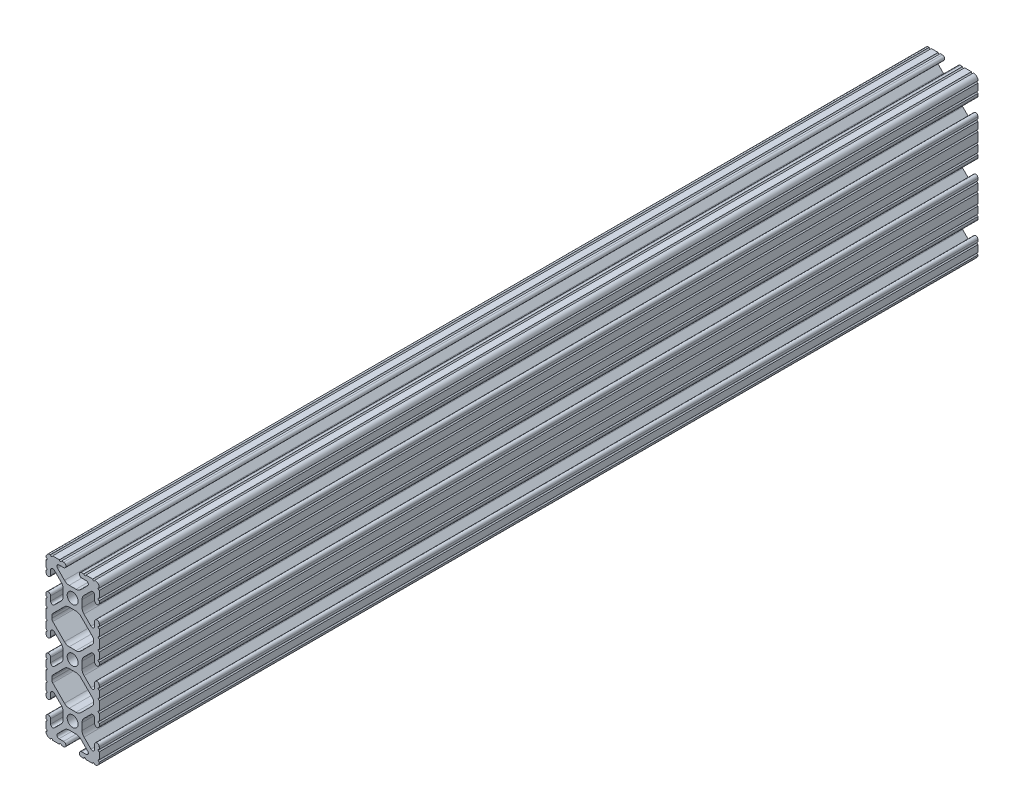
from build123d import *

# Parameters (mm, degrees)
SKETCH1_R           = 2.6035
BOSS_EXTRUDE1_DEPTH = 419.1


with BuildPart() as part:
    # Sketch1 → Boss-Extrude1 (new body)
    with BuildSketch(Plane.XY):
        with BuildLine():
            Line((-6.3246, 38.1), (-9.5504, 38.1))
            ThreePointArc((-9.5504, 38.1), (-10.0584, 37.592), (-10.5664, 38.1))
            ThreePointArc((-10.5664, 38.1), (-12.082677406, 37.482677406), (-12.7, 35.9664))
            ThreePointArc((-12.7, 35.9664), (-12.192, 35.4584), (-12.7, 34.9504))
            Line((-12.7, 34.9504), (-12.7, 31.7246))
            ThreePointArc((-12.7, 31.7246), (-12.192, 31.2166), (-12.7, 30.7086))
            Line((-12.7, 30.7086), (-12.7, 29.702307889))
            ThreePointArc((-12.7, 29.702307889), (-11.5951, 28.597407889), (-10.4902, 29.702307889))
            Line((-10.4902, 29.702307889), (-10.4902, 31.874794456))
            ThreePointArc((-10.4902, 31.874794456), (-9.863006367, 32.813456061), (-8.75577951, 32.593214945))
            Line((-8.75577951, 32.593214945), (-5.43843597, 29.275871405))
            ThreePointArc((-5.43843597, 29.275871405), (-4.750182484, 28.245827272), (-4.5085, 27.030807374))
            Line((-4.5085, 27.030807374), (-4.5085, 23.769192626))
            ThreePointArc((-4.5085, 23.769192626), (-4.750182484, 22.554172728), (-5.43843597, 21.524128595))
            Line((-5.43843597, 21.524128595), (-8.75577951, 18.206785055))
            ThreePointArc((-8.75577951, 18.206785055), (-9.863006367, 17.986543939), (-10.4902, 18.925205544))
            Line((-10.4902, 18.925205544), (-10.4902, 21.097692111))
            ThreePointArc((-10.4902, 21.097692111), (-11.5951, 22.202592111), (-12.7, 21.097692111))
            Line((-12.7, 21.097692111), (-12.7, 20.0914))
            ThreePointArc((-12.7, 20.0914), (-12.192, 19.5834), (-12.7, 19.0754))
            Line((-12.7, 19.0754), (-12.7, 15.8496))
            ThreePointArc((-12.7, 15.8496), (-12.192, 15.3416), (-12.7, 14.8336))
            Line((-12.7, 14.8336), (-12.7, 10.5664))
            ThreePointArc((-12.7, 10.5664), (-12.192, 10.0584), (-12.7, 9.5504))
            Line((-12.7, 9.5504), (-12.7, 6.3246))
            ThreePointArc((-12.7, 6.3246), (-12.192, 5.8166), (-12.7, 5.3086))
            Line((-12.7, 5.3086), (-12.7, 4.302307889))
            ThreePointArc((-12.7, 4.302307889), (-11.5951, 3.197407889), (-10.4902, 4.302307889))
            Line((-10.4902, 4.302307889), (-10.4902, 6.474794456))
            ThreePointArc((-10.4902, 6.474794456), (-9.863006367, 7.413456061), (-8.75577951, 7.193214945))
            Line((-8.75577951, 7.193214945), (-5.43843597, 3.875871405))
            ThreePointArc((-5.43843597, 3.875871405), (-4.750182484, 2.845827272), (-4.5085, 1.630807374))
            Line((-4.5085, 1.630807374), (-4.5085, -1.630807374))
            ThreePointArc((-4.5085, -1.630807374), (-4.750182484, -2.845827272), (-5.43843597, -3.875871405))
            Line((-5.43843597, -3.875871405), (-8.75577951, -7.193214945))
            ThreePointArc((-8.75577951, -7.193214945), (-9.863006367, -7.413456061), (-10.4902, -6.474794456))
            Line((-10.4902, -6.474794456), (-10.4902, -4.302307889))
            ThreePointArc((-10.4902, -4.302307889), (-11.5951, -3.197407889), (-12.7, -4.302307889))
            Line((-12.7, -4.302307889), (-12.7, -5.3086))
            ThreePointArc((-12.7, -5.3086), (-12.192, -5.8166), (-12.7, -6.3246))
            Line((-12.7, -6.3246), (-12.7, -9.5504))
            ThreePointArc((-12.7, -9.5504), (-12.192, -10.0584), (-12.7, -10.5664))
            Line((-12.7, -10.5664), (-12.7, -14.8336))
            ThreePointArc((-12.7, -14.8336), (-12.192, -15.3416), (-12.7, -15.8496))
            Line((-12.7, -15.8496), (-12.7, -19.0754))
            ThreePointArc((-12.7, -19.0754), (-12.192, -19.5834), (-12.7, -20.0914))
            Line((-12.7, -20.0914), (-12.7, -21.097692111))
            ThreePointArc((-12.7, -21.097692111), (-11.5951, -22.202592111), (-10.4902, -21.097692111))
            Line((-10.4902, -21.097692111), (-10.4902, -18.925205544))
            ThreePointArc((-10.4902, -18.925205544), (-9.863006367, -17.986543939), (-8.75577951, -18.206785055))
            Line((-8.75577951, -18.206785055), (-5.43843597, -21.524128595))
            ThreePointArc((-5.43843597, -21.524128595), (-4.750182484, -22.554172728), (-4.5085, -23.769192626))
            Line((-4.5085, -23.769192626), (-4.5085, -27.030807374))
            ThreePointArc((-4.5085, -27.030807374), (-4.750182484, -28.245827272), (-5.43843597, -29.275871405))
            Line((-5.43843597, -29.275871405), (-8.75577951, -32.593214945))
            ThreePointArc((-8.75577951, -32.593214945), (-9.863006367, -32.813456061), (-10.4902, -31.874794456))
            Line((-10.4902, -31.874794456), (-10.4902, -29.702307889))
            ThreePointArc((-10.4902, -29.702307889), (-11.5951, -28.597407889), (-12.7, -29.702307889))
            Line((-12.7, -29.702307889), (-12.7, -30.7086))
            ThreePointArc((-12.7, -30.7086), (-12.192, -31.2166), (-12.7, -31.7246))
            Line((-12.7, -31.7246), (-12.7, -34.9504))
            ThreePointArc((-12.7, -34.9504), (-12.192, -35.4584), (-12.7, -35.9664))
            ThreePointArc((-12.7, -35.9664), (-12.082677406, -37.482677406), (-10.5664, -38.1))
            ThreePointArc((-10.5664, -38.1), (-10.0584, -37.592), (-9.5504, -38.1))
            Line((-9.5504, -38.1), (-6.3246, -38.1))
            ThreePointArc((-6.3246, -38.1), (-5.8166, -37.592), (-5.3086, -38.1))
            Line((-5.3086, -38.1), (-4.302307889, -38.1))
            ThreePointArc((-4.302307889, -38.1), (-3.197407889, -36.9951), (-4.302307889, -35.8902))
            Line((-4.302307889, -35.8902), (-6.474794456, -35.8902))
            ThreePointArc((-6.474794456, -35.8902), (-7.413456061, -35.263006367), (-7.193214945, -34.15577951))
            Line((-7.193214945, -34.15577951), (-3.875871405, -30.83843597))
            ThreePointArc((-3.875871405, -30.83843597), (-2.845827272, -30.150182484), (-1.630807374, -29.9085))
            Line((-1.630807374, -29.9085), (1.630807374, -29.9085))
            ThreePointArc((1.630807374, -29.9085), (2.845827272, -30.150182484), (3.875871405, -30.83843597))
            Line((3.875871405, -30.83843597), (7.193214945, -34.15577951))
            ThreePointArc((7.193214945, -34.15577951), (7.413456061, -35.263006367), (6.474794456, -35.8902))
            Line((6.474794456, -35.8902), (4.302307889, -35.8902))
            ThreePointArc((4.302307889, -35.8902), (3.197407889, -36.9951), (4.302307889, -38.1))
            Line((4.302307889, -38.1), (5.3086, -38.1))
            ThreePointArc((5.3086, -38.1), (5.8166, -37.592), (6.3246, -38.1))
            Line((6.3246, -38.1), (9.5504, -38.1))
            ThreePointArc((9.5504, -38.1), (10.0584, -37.592), (10.5664, -38.1))
            ThreePointArc((10.5664, -38.1), (12.082677406, -37.482677406), (12.7, -35.9664))
            ThreePointArc((12.7, -35.9664), (12.192, -35.4584), (12.7, -34.9504))
            Line((12.7, -34.9504), (12.7, -31.7246))
            ThreePointArc((12.7, -31.7246), (12.192, -31.2166), (12.7, -30.7086))
            Line((12.7, -30.7086), (12.7, -29.702307918))
            ThreePointArc((12.7, -29.702307918), (11.5951, -28.597407918), (10.4902, -29.702307918))
            Line((10.4902, -29.702307918), (10.4902, -31.874794456))
            ThreePointArc((10.4902, -31.874794456), (9.863006367, -32.813456061), (8.75577951, -32.593214945))
            Line((8.75577951, -32.593214945), (5.43843597, -29.275871405))
            ThreePointArc((5.43843597, -29.275871405), (4.750182484, -28.245827272), (4.5085, -27.030807374))
            Line((4.5085, -27.030807374), (4.5085, -23.769192626))
            ThreePointArc((4.5085, -23.769192626), (4.750182484, -22.554172728), (5.43843597, -21.524128595))
            Line((5.43843597, -21.524128595), (8.75577951, -18.206785055))
            ThreePointArc((8.75577951, -18.206785055), (9.863006367, -17.986543939), (10.4902, -18.925205544))
            Line((10.4902, -18.925205544), (10.4902, -21.097692058))
            ThreePointArc((10.4902, -21.097692058), (11.5951, -22.202592058), (12.7, -21.097692058))
            Line((12.7, -21.097692058), (12.7, -20.0914))
            ThreePointArc((12.7, -20.0914), (12.192, -19.5834), (12.7, -19.0754))
            Line((12.7, -19.0754), (12.7, -15.8496))
            ThreePointArc((12.7, -15.8496), (12.192, -15.3416), (12.7, -14.8336))
            Line((12.7, -14.8336), (12.7, -10.5664))
            ThreePointArc((12.7, -10.5664), (12.192, -10.0584), (12.7, -9.5504))
            Line((12.7, -9.5504), (12.7, -6.3246))
            ThreePointArc((12.7, -6.3246), (12.192, -5.8166), (12.7, -5.3086))
            Line((12.7, -5.3086), (12.7, -4.302307889))
            ThreePointArc((12.7, -4.302307889), (11.5951, -3.197407889), (10.4902, -4.302307889))
            Line((10.4902, -4.302307889), (10.4902, -6.474794456))
            ThreePointArc((10.4902, -6.474794456), (9.863006367, -7.413456061), (8.75577951, -7.193214945))
            Line((8.75577951, -7.193214945), (5.43843597, -3.875871405))
            ThreePointArc((5.43843597, -3.875871405), (4.750182484, -2.845827272), (4.5085, -1.630807374))
            Line((4.5085, -1.630807374), (4.5085, 1.630807374))
            ThreePointArc((4.5085, 1.630807374), (4.750182484, 2.845827272), (5.43843597, 3.875871405))
            Line((5.43843597, 3.875871405), (8.75577951, 7.193214945))
            ThreePointArc((8.75577951, 7.193214945), (9.863006367, 7.413456061), (10.4902, 6.474794456))
            Line((10.4902, 6.474794456), (10.4902, 4.302307889))
            ThreePointArc((10.4902, 4.302307889), (11.5951, 3.197407889), (12.7, 4.302307889))
            Line((12.7, 4.302307889), (12.7, 5.3086))
            ThreePointArc((12.7, 5.3086), (12.192, 5.8166), (12.7, 6.3246))
            Line((12.7, 6.3246), (12.7, 9.5504))
            ThreePointArc((12.7, 9.5504), (12.192, 10.0584), (12.7, 10.5664))
            Line((12.7, 10.5664), (12.7, 14.8336))
            ThreePointArc((12.7, 14.8336), (12.192, 15.3416), (12.7, 15.8496))
            Line((12.7, 15.8496), (12.7, 19.0754))
            ThreePointArc((12.7, 19.0754), (12.192, 19.5834), (12.7, 20.0914))
            Line((12.7, 20.0914), (12.7, 21.097692082))
            ThreePointArc((12.7, 21.097692082), (11.5951, 22.202592082), (10.4902, 21.097692082))
            Line((10.4902, 21.097692082), (10.4902, 18.925205544))
            ThreePointArc((10.4902, 18.925205544), (9.863006367, 17.986543939), (8.75577951, 18.206785055))
            Line((8.75577951, 18.206785055), (5.43843597, 21.524128595))
            ThreePointArc((5.43843597, 21.524128595), (4.750182484, 22.554172728), (4.5085, 23.769192626))
            Line((4.5085, 23.769192626), (4.5085, 27.030807374))
            ThreePointArc((4.5085, 27.030807374), (4.750182484, 28.245827272), (5.43843597, 29.275871405))
            Line((5.43843597, 29.275871405), (8.75577951, 32.593214945))
            ThreePointArc((8.75577951, 32.593214945), (9.863006367, 32.813456061), (10.4902, 31.874794456))
            Line((10.4902, 31.874794456), (10.4902, 29.702307889))
            ThreePointArc((10.4902, 29.702307889), (11.5951, 28.597407889), (12.7, 29.702307889))
            Line((12.7, 29.702307889), (12.7, 30.7086))
            ThreePointArc((12.7, 30.7086), (12.192, 31.2166), (12.7, 31.7246))
            Line((12.7, 31.7246), (12.7, 34.9504))
            ThreePointArc((12.7, 34.9504), (12.192, 35.4584), (12.7, 35.9664))
            ThreePointArc((12.7, 35.9664), (12.082677406, 37.482677406), (10.5664, 38.1))
            ThreePointArc((10.5664, 38.1), (10.0584, 37.592), (9.5504, 38.1))
            Line((9.5504, 38.1), (6.3246, 38.1))
            ThreePointArc((6.3246, 38.1), (5.8166, 37.592), (5.3086, 38.1))
            Line((5.3086, 38.1), (4.302307889, 38.1))
            ThreePointArc((4.302307889, 38.1), (3.197407889, 36.9951), (4.302307889, 35.8902))
            Line((4.302307889, 35.8902), (6.474794456, 35.8902))
            ThreePointArc((6.474794456, 35.8902), (7.413456061, 35.263006367), (7.193214945, 34.15577951))
            Line((7.193214945, 34.15577951), (3.875871405, 30.83843597))
            ThreePointArc((3.875871405, 30.83843597), (2.845827272, 30.150182484), (1.630807374, 29.9085))
            Line((1.630807374, 29.9085), (-1.630807374, 29.9085))
            ThreePointArc((-1.630807374, 29.9085), (-2.845827272, 30.150182484), (-3.875871405, 30.83843597))
            Line((-3.875871405, 30.83843597), (-7.193214945, 34.15577951))
            ThreePointArc((-7.193214945, 34.15577951), (-7.413456061, 35.263006367), (-6.474794456, 35.8902))
            Line((-6.474794456, 35.8902), (-4.302307889, 35.8902))
            ThreePointArc((-4.302307889, 35.8902), (-3.197407889, 36.9951), (-4.302307889, 38.1))
            Line((-4.302307889, 38.1), (-5.3086, 38.1))
            ThreePointArc((-5.3086, 38.1), (-5.8166, 37.592), (-6.3246, 38.1))
        make_face()
        with Locations((0, 25.4)):
            Circle(SKETCH1_R, mode=Mode.SUBTRACT)
        with Locations((0, -25.4)):
            Circle(SKETCH1_R, mode=Mode.SUBTRACT)
        Circle(SKETCH1_R, mode=Mode.SUBTRACT)
        with BuildLine():
            Line((-9.9314, 12.146268083), (-9.9314, 13.253731917))
            ThreePointArc((-9.9314, 13.253731917), (-9.811525488, 13.856381786), (-9.470151759, 14.367283676))
            Line((-9.470151759, 14.367283676), (-3.875871405, 19.96156403))
            ThreePointArc((-3.875871405, 19.96156403), (-2.845827272, 20.649817516), (-1.630807374, 20.8915))
            Line((-1.630807374, 20.8915), (1.630807374, 20.8915))
            ThreePointArc((1.630807374, 20.8915), (2.845827272, 20.649817516), (3.875871405, 19.96156403))
            Line((3.875871405, 19.96156403), (9.470151759, 14.367283676))
            ThreePointArc((9.470151759, 14.367283676), (9.811525488, 13.856381786), (9.9314, 13.253731917))
            Line((9.9314, 13.253731917), (9.9314, 12.146268083))
            ThreePointArc((9.9314, 12.146268083), (9.811525488, 11.543618214), (9.470151759, 11.032716324))
            Line((9.470151759, 11.032716324), (3.875871405, 5.43843597))
            ThreePointArc((3.875871405, 5.43843597), (2.845827272, 4.750182484), (1.630807374, 4.5085))
            Line((1.630807374, 4.5085), (-1.630807374, 4.5085))
            ThreePointArc((-1.630807374, 4.5085), (-2.845827272, 4.750182484), (-3.875871405, 5.43843597))
            Line((-3.875871405, 5.43843597), (-9.470151759, 11.032716324))
            ThreePointArc((-9.470151759, 11.032716324), (-9.811525488, 11.543618214), (-9.9314, 12.146268083))
        make_face(mode=Mode.SUBTRACT)
        with BuildLine():
            Line((-9.9314, -13.253731917), (-9.9314, -12.146268083))
            ThreePointArc((-9.9314, -12.146268083), (-9.811525488, -11.543618214), (-9.470151759, -11.032716324))
            Line((-9.470151759, -11.032716324), (-3.875871405, -5.43843597))
            ThreePointArc((-3.875871405, -5.43843597), (-2.845827272, -4.750182484), (-1.630807374, -4.5085))
            Line((-1.630807374, -4.5085), (1.630807374, -4.5085))
            ThreePointArc((1.630807374, -4.5085), (2.845827272, -4.750182484), (3.875871405, -5.43843597))
            Line((3.875871405, -5.43843597), (9.470151759, -11.032716324))
            ThreePointArc((9.470151759, -11.032716324), (9.811525488, -11.543618214), (9.9314, -12.146268083))
            Line((9.9314, -12.146268083), (9.9314, -13.253731917))
            ThreePointArc((9.9314, -13.253731917), (9.811525488, -13.856381786), (9.470151759, -14.367283676))
            Line((9.470151759, -14.367283676), (3.875871405, -19.96156403))
            ThreePointArc((3.875871405, -19.96156403), (2.845827272, -20.649817516), (1.630807374, -20.8915))
            Line((1.630807374, -20.8915), (-1.630807374, -20.8915))
            ThreePointArc((-1.630807374, -20.8915), (-2.845827272, -20.649817516), (-3.875871405, -19.96156403))
            Line((-3.875871405, -19.96156403), (-9.470151759, -14.367283676))
            ThreePointArc((-9.470151759, -14.367283676), (-9.811525488, -13.856381786), (-9.9314, -13.253731917))
        make_face(mode=Mode.SUBTRACT)
    extrude(amount=-BOSS_EXTRUDE1_DEPTH)


solid = part.part
